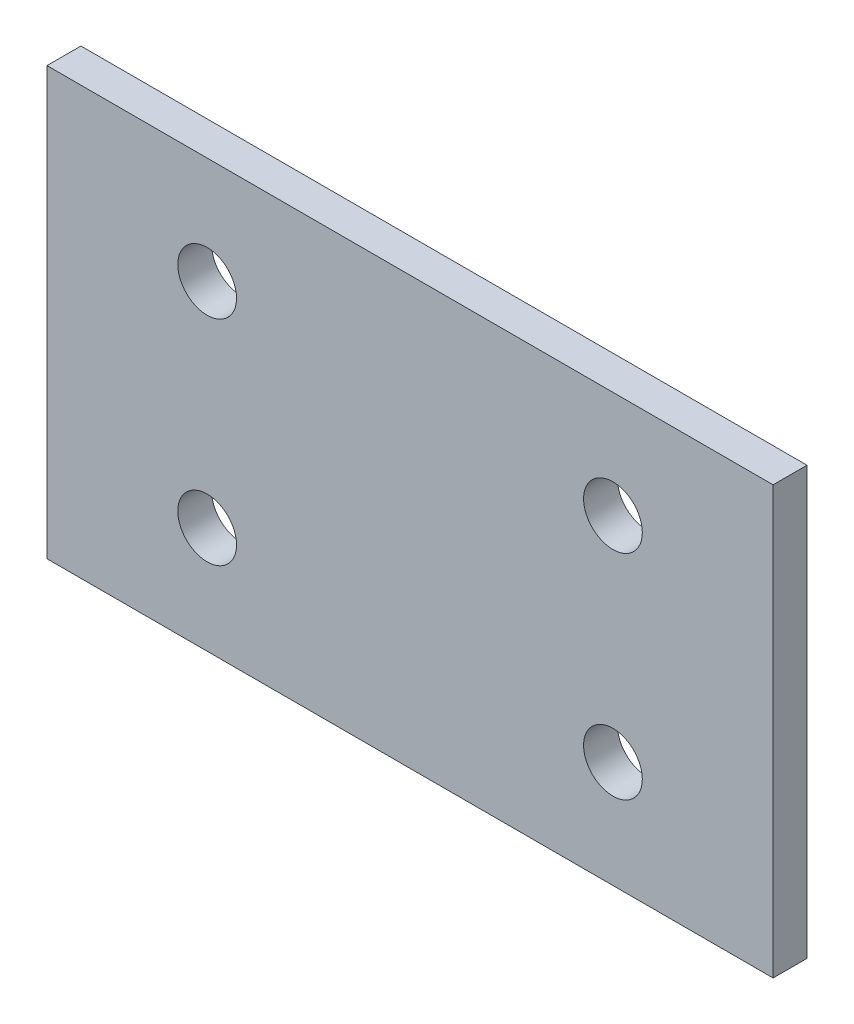
from build123d import *

# Parameters (mm, degrees)
SKETCH1_W           = 68
SKETCH1_H           = 40
BOSS_EXTRUDE1_DEPTH = 3.175
SKETCH2_R           = 2.75
CUT_EXTRUDE1_DEPTH  = 4.175


with BuildPart() as part:
    # Sketch1 → Boss-Extrude1 (new body)
    with BuildSketch(Plane.XY):
        with Locations((34, 20)):
            Rectangle(SKETCH1_W, SKETCH1_H)
    extrude(amount=BOSS_EXTRUDE1_DEPTH)

    # Sketch2 → Cut-Extrude1 (cut, through all)
    with BuildSketch(Plane.XY.offset(3.175)):
        with Locations((15, 30)):
            Circle(SKETCH2_R)
        with Locations((53, 30)):
            Circle(SKETCH2_R)
        with Locations((15, 10)):
            Circle(SKETCH2_R)
        with Locations((53, 10)):
            Circle(SKETCH2_R)
    extrude(amount=-CUT_EXTRUDE1_DEPTH, mode=Mode.SUBTRACT)


solid = part.part
